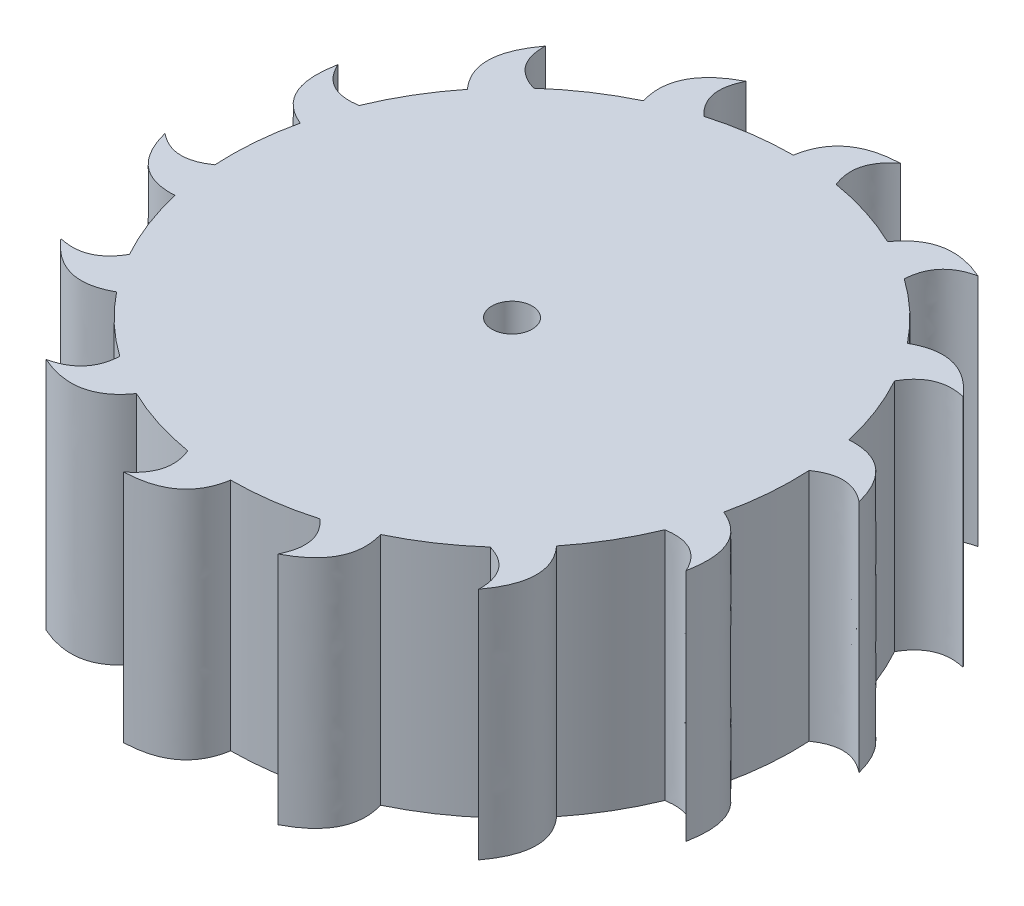
from build123d import *

# Parameters (mm, degrees)
SKETCH1_R           = 30
BOSS_EXTRUDE1_DEPTH = 25
SKETCH2_R           = 2.15
CUT_EXTRUDE1_DEPTH  = 26
BOSS_EXTRUDE2_DEPTH = 25
CIRPATTERN1_COUNT   = 14


with BuildPart() as part:
    # Sketch1 → Boss-Extrude1 (new body)
    with BuildSketch(Plane(origin=(0, 0, 0), x_dir=(1, 0, 0), z_dir=(0, 1, 0))):
        Circle(SKETCH1_R)
    extrude(amount=BOSS_EXTRUDE1_DEPTH)

    # Sketch2 → Cut-Extrude1 (cut, through all)
    with BuildSketch(Plane(origin=(0, 25, 0), x_dir=(1, 0, 0), z_dir=(0, 1, 0))):
        Circle(SKETCH2_R)
    extrude(amount=-CUT_EXTRUDE1_DEPTH, mode=Mode.SUBTRACT)

    # Sketch3 → Boss-Extrude2 (add, through all)
    with BuildSketch(Plane(origin=(0, 25, 0), x_dir=(1, 0, 0), z_dir=(0, 1, 0))):
        with BuildLine():
            Line((0, 30), (3.378956964, 26.809860285))
            Line((3.378956964, 26.809860285), (4.977675541, 29.584163774))
            add(Edge.make_bspline(
                [(6.463090103, 34.958464686), (3.678095749, 32.81046922), (4.977675541, 29.584163774)],
                knots=[0, 0, 0, 1, 1, 1], degree=2))
            add(Edge.make_bspline(
                [(0, 30), (0.774451362, 34.774618744), (6.463090103, 34.958464686)],
                knots=[0, 0, 0, 1, 1, 1], degree=2))
        make_face()
    boss_extrude2 = extrude(amount=-BOSS_EXTRUDE2_DEPTH)

    # CirPattern1: Boss-Extrude2 ×14 about axis
    cirpattern1_axis = Axis((0, 0, 0), (0, 1, 0))
    for i in range(1, CIRPATTERN1_COUNT):
        add(boss_extrude2.rotate(cirpattern1_axis, i * 360 / CIRPATTERN1_COUNT))


solid = part.part
